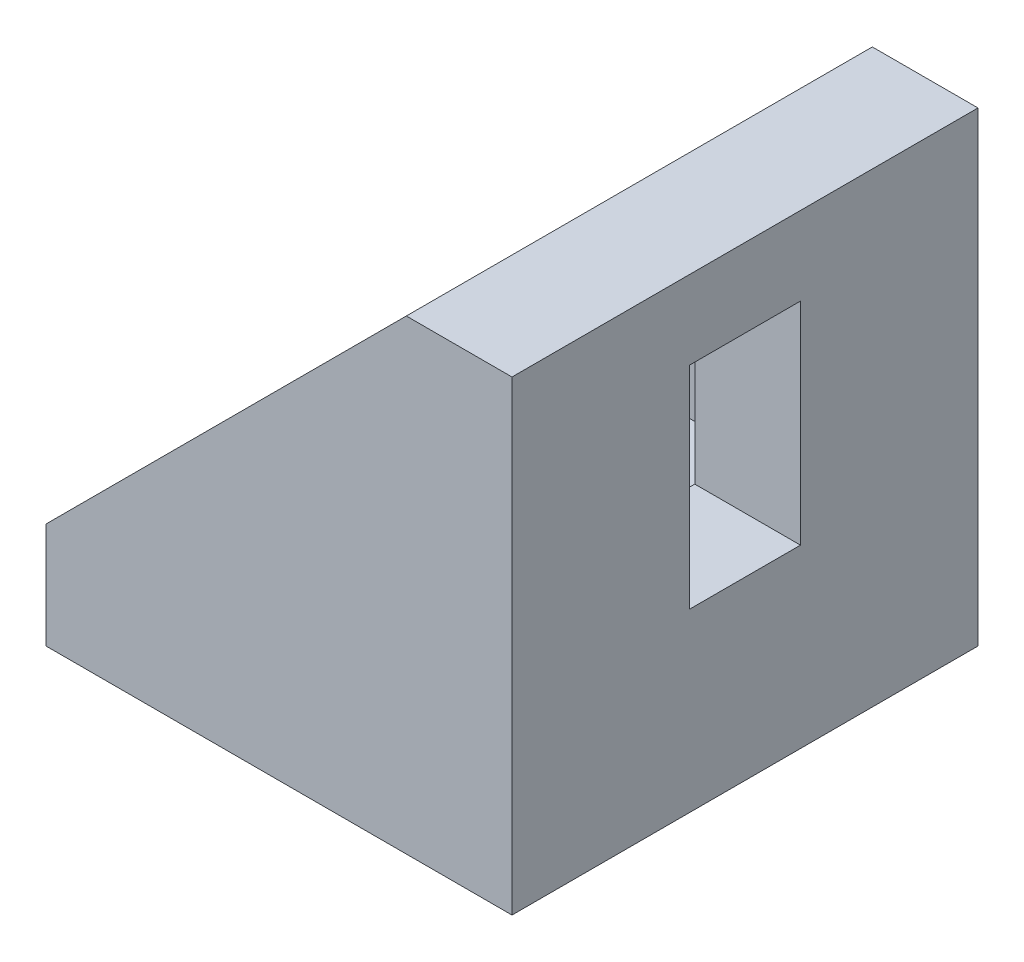
from build123d import *

# Parameters (mm, degrees)
BOSS_EXTRUDE1_DEPTH = 21
BOSS_EXTRUDE2_DEPTH = 4.7625
SKETCH3_W           = 19.05
SKETCH3_H           = 10
CUT_EXTRUDE1_DEPTH  = 10.525


with BuildPart() as part:
    # Sketch1 → Boss-Extrude1 (new body)
    with BuildSketch(Plane.XY):
        Polygon((0, 0), (-42, 0), (-42, 9.525), (-9.525, 9.525), (-9.525, 42), (0, 42), align=None)
    boss_extrude1 = extrude(amount=BOSS_EXTRUDE1_DEPTH)

    # Sketch2 → Boss-Extrude2 (add)
    with BuildSketch(Plane.XY.offset(21)):
        Polygon((-9.525, 42), (-42, 9.525), (-9.525, 9.525), align=None)
    boss_extrude2 = extrude(amount=-BOSS_EXTRUDE2_DEPTH)

    # Mirror1: Boss-Extrude1, Boss-Extrude2 across plane
    add(boss_extrude1.mirror(Plane(origin=(0, 0, 0), x_dir=(1, 0, 0), z_dir=(0, 0, -1))))
    add(boss_extrude2.mirror(Plane(origin=(0, 0, 0), x_dir=(1, 0, 0), z_dir=(0, 0, -1))))

    # Sketch3 → Cut-Extrude1 (cut, through all)
    with BuildSketch(Plane(origin=(0, 9.525, 0), x_dir=(1, 0, 0), z_dir=(0, 1, 0))):
        with Locations((-25.4, 0)):
            Rectangle(SKETCH3_W, SKETCH3_H)
    cut_extrude1 = extrude(amount=-CUT_EXTRUDE1_DEPTH, mode=Mode.SUBTRACT)

    # Mirror2: Cut-Extrude1 across plane
    add(cut_extrude1.mirror(Plane(origin=(0, 0, 0), x_dir=(0, 0, 1), z_dir=(0.707106781, 0.707106781, 0))), mode=Mode.SUBTRACT)


solid = part.part
